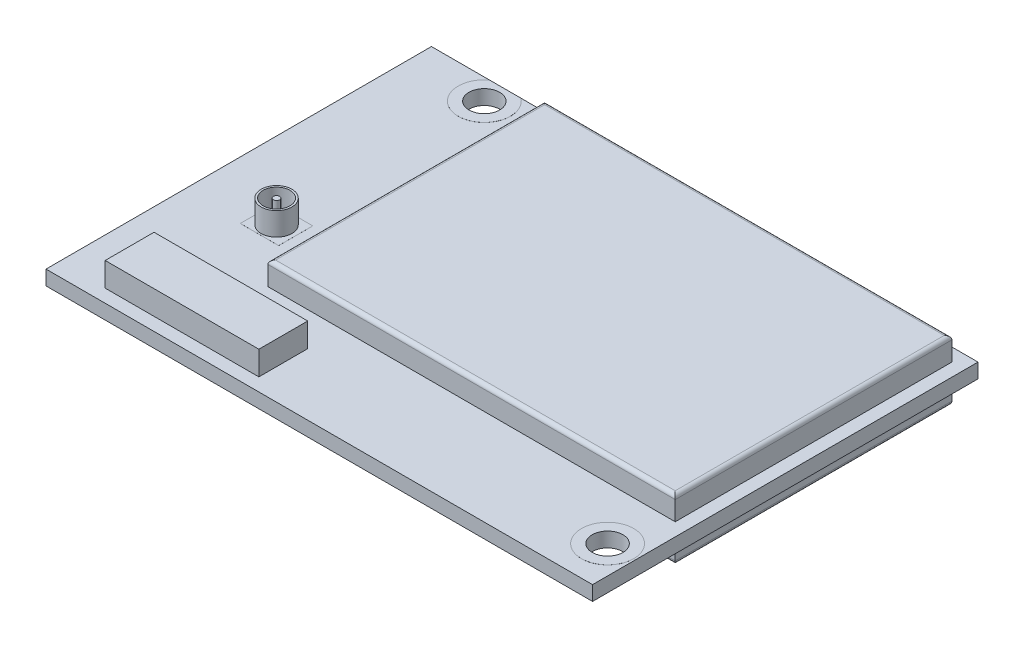
from build123d import *

# Parameters (mm, degrees)
SKETCH1_W           = 35.56
SKETCH1_H           = 25.08
BOSS_EXTRUDE1_DEPTH = 0.95
SKETCH2_W           = 26.5
SKETCH2_H           = 18
BOSS_EXTRUDE2_DEPTH = 1.5
BOSS_EXTRUDE3_DEPTH = 1.5
SKETCH4_W           = 10
SKETCH4_H           = 3.18
BOSS_EXTRUDE4_DEPTH = 1.56
SKETCH5_R           = 1
SKETCH5_R_2         = 0.875
SKETCH5_R_3         = 0.2
BOSS_EXTRUDE5_DEPTH = 1.5
SKETCH6_W           = 15.5
SKETCH6_H           = 1.85
SKETCH6_W_2         = 15
SKETCH6_H_2         = 1.35
BOSS_EXTRUDE6_DEPTH = 0.75
SKETCH7_R           = 1
CUT_EXTRUDE1_DEPTH  = 3.51
SKETCH8_R           = 1
CUT_EXTRUDE2_DEPTH  = 3.45
SKETCH9_R           = 1.7
SKETCH9_R_2         = 1
BOSS_EXTRUDE7_DEPTH = 0.0025
SKETCH10_R          = 1.7
SKETCH10_R_2        = 1
BOSS_EXTRUDE8_DEPTH = 0.0025
FILLET1_R           = 0.25
SKETCH11_W          = 2.494146152
SKETCH11_H          = 2.219681882
BOSS_EXTRUDE9_DEPTH = 0.0025


with BuildPart() as part:
    # Sketch1 → Boss-Extrude1 (new body)
    with BuildSketch(Plane(origin=(0, 0, 0), x_dir=(1, 0, 0), z_dir=(0, 1, 0))):
        Rectangle(SKETCH1_W, SKETCH1_H)
    extrude(amount=BOSS_EXTRUDE1_DEPTH)

    # Sketch2 → Boss-Extrude2 (add)
    with BuildSketch(Plane(origin=(0, 0.95, 0), x_dir=(1, 0, 0), z_dir=(0, 1, 0))):
        with Locations((3.68, 2.69)):
            Rectangle(SKETCH2_W, SKETCH2_H)
    extrude(amount=BOSS_EXTRUDE2_DEPTH)

    # Sketch3 → Boss-Extrude3 (add)
    with BuildSketch(Plane.XZ):
        Polygon((16.93, 6.31), (16.93, -11.69), (-11.22, -11.69), (-11.22, -8.69), (-16.47, -8.69), (-16.47, 6.31), align=None)
    extrude(amount=BOSS_EXTRUDE3_DEPTH)

    # Sketch4 → Boss-Extrude4 (add)
    with BuildSketch(Plane(origin=(0, 0.95, 0), x_dir=(1, 0, 0), z_dir=(0, 1, 0))):
        with Locations((-9.78, -10.1)):
            Rectangle(SKETCH4_W, SKETCH4_H)
    extrude(amount=BOSS_EXTRUDE4_DEPTH)

    # Sketch5 → Boss-Extrude5 (add)
    with BuildSketch(Plane(origin=(0, 0.95, 0), x_dir=(1, 0, 0), z_dir=(0, 1, 0))):
        with Locations((-12.78, -2.54)):
            Circle(SKETCH5_R)
        with Locations((-12.78, -2.54)):
            Circle(SKETCH5_R_2, mode=Mode.SUBTRACT)
        with Locations((-12.78, -2.54)):
            Circle(SKETCH5_R_3)
    extrude(amount=BOSS_EXTRUDE5_DEPTH)

    # Sketch6 → Boss-Extrude6 (add)
    with BuildSketch(Plane.XZ):
        with Locations((5.73, 9.315)):
            Rectangle(SKETCH6_W, SKETCH6_H)
        with Locations((5.73, 9.315)):
            Rectangle(SKETCH6_W_2, SKETCH6_H_2, mode=Mode.SUBTRACT)
    extrude(amount=BOSS_EXTRUDE6_DEPTH)

    # Sketch7 → Cut-Extrude1 (cut, through all)
    with BuildSketch(Plane.XZ):
        with Locations((15.96, 9.74)):
            Circle(SKETCH7_R)
    extrude(amount=-CUT_EXTRUDE1_DEPTH, mode=Mode.SUBTRACT)

    # Sketch8 → Cut-Extrude2 (cut, through all)
    with BuildSketch(Plane(origin=(0, 0.95, 0), x_dir=(1, 0, 0), z_dir=(0, 1, 0))):
        with Locations((-12.98, 11.18)):
            Circle(SKETCH8_R)
    extrude(amount=-CUT_EXTRUDE2_DEPTH, mode=Mode.SUBTRACT)

    # Sketch9 → Boss-Extrude7 (add)
    with BuildSketch(Plane(origin=(0, 0.95, 0), x_dir=(1, 0, 0), z_dir=(0, 1, 0))):
        with Locations((15.96, -9.74)):
            Circle(SKETCH9_R)
        with Locations((15.96, -9.74)):
            Circle(SKETCH9_R_2, mode=Mode.SUBTRACT)
        with BuildLine():
            Line((-11.96, 12.54), (-14, 12.54))
            ThreePointArc((-14, 12.54), (-12.98, 9.48), (-11.96, 12.54))
        make_face()
        with Locations((-12.98, 11.18)):
            Circle(SKETCH9_R_2, mode=Mode.SUBTRACT)
    extrude(amount=BOSS_EXTRUDE7_DEPTH)

    # Sketch10 → Boss-Extrude8 (add)
    with BuildSketch(Plane.XZ):
        with Locations((15.96, 9.74)):
            Circle(SKETCH10_R)
        with Locations((15.96, 9.74)):
            Circle(SKETCH10_R_2, mode=Mode.SUBTRACT)
        with BuildLine():
            Line((-11.96, -12.54), (-14, -12.54))
            ThreePointArc((-14, -12.54), (-12.98, -9.48), (-11.96, -12.54))
        make_face()
        with Locations((-12.98, -11.18)):
            Circle(SKETCH10_R_2, mode=Mode.SUBTRACT)
    extrude(amount=BOSS_EXTRUDE8_DEPTH)

    # Fillet1
    fillet1_edges = [part.edges().sort_by_distance(p)[0] for p in [
        (-9.57, 2.45, -2.69),
        (3.68, 2.45, 6.31),
        (16.93, 2.45, -2.69),
        (3.68, 2.45, -11.69),
        (2.855, -1.5, -11.69),
        (16.93, -1.5, -2.69),
        (0.23, -1.5, 6.31),
        (-16.47, -1.5, -1.19),
        (-13.845, -1.5, -8.69),
        (-11.22, -1.5, -10.19),
    ]]
    fillet(fillet1_edges, radius=FILLET1_R)

    # Sketch11 → Boss-Extrude9 (add)
    with BuildSketch(Plane(origin=(0, 0.95, 0), x_dir=(1, 0, 0), z_dir=(0, 1, 0))):
        with Locations((-12.78, -2.54)):
            Rectangle(SKETCH11_W, SKETCH11_H)
    extrude(amount=BOSS_EXTRUDE9_DEPTH)


solid = part.part
